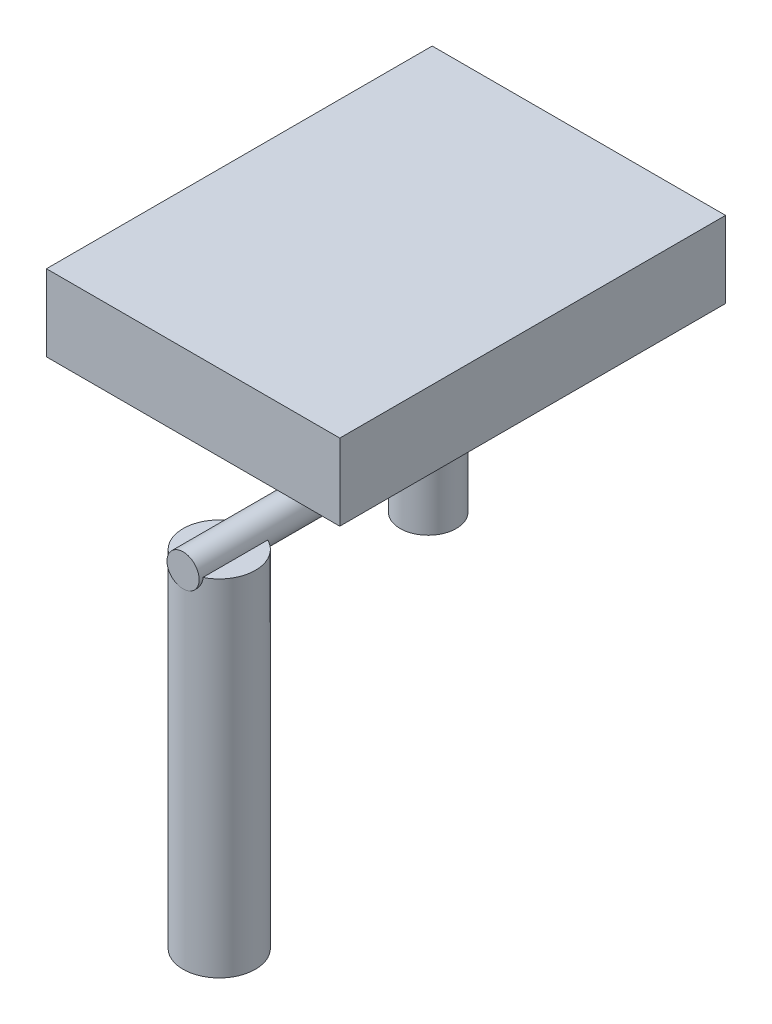
from build123d import *

# Parameters (mm, degrees)
ESQUISSE1_W        = 365
ESQUISSE1_H        = 95
BOSS_EXTRU_1_DEPTH = 480
ESQUISSE3_R        = 35
BOSS_EXTRU_2_DEPTH = 235
BOSS_EXTRU_3_REACH = 482
ESQUISSE4_R        = 20
BOSS_EXTRU_4_START = 145
ESQUISSE5_R        = 45
BOSS_EXTRU_4_DEPTH = 430
ESQUISSE6_W        = 205
ESQUISSE6_H        = 70
BOSS_EXTRU_5_DEPTH = 55
ESQUISSE7_R        = 60
BOSS_EXTRU_6_DEPTH = 50


with BuildPart() as part:
    # Esquisse1 → Boss.-Extru.1 (new body)
    with BuildSketch(Plane.XY):
        with Locations((103.348235656, -10.607228484)):
            Rectangle(ESQUISSE1_W, ESQUISSE1_H)
    extrude(amount=BOSS_EXTRU_1_DEPTH)

    # Esquisse3 → Boss.-Extru.2 (add)
    with BuildSketch(Plane.XZ.offset(58.107228484)):
        with Locations((90.848235656, 175)):
            Circle(ESQUISSE3_R)
    extrude(amount=BOSS_EXTRU_2_DEPTH)

    # Esquisse4 → Boss.-Extru.3 (add, up to next)
    with BuildSketch(Plane.XY.offset(480), mode=Mode.PRIVATE) as boss_extru_3_sk1:
        with Locations((90.848235656, -203.107228484)):
            Circle(ESQUISSE4_R)
    boss_extru_3_tool1 = extrude(boss_extru_3_sk1.sketch, amount=-BOSS_EXTRU_3_REACH, mode=Mode.PRIVATE) - part.part
    add(boss_extru_3_tool1.solids().sort_by_distance((90.848236, -203.107228, 480))[0])

    # Esquisse6 → Boss.-Extru.5 (add)
    with BuildSketch(Plane.XZ.offset(58.107228484)):
        with Locations((23.348235656, 175)):
            Rectangle(ESQUISSE6_W, ESQUISSE6_H)
    extrude(amount=BOSS_EXTRU_5_DEPTH)

    # Esquisse7 → Boss.-Extru.6 (add)
    with BuildSketch(Plane.XZ.offset(58.107228484)):
        with Locations((90.848235656, 175)):
            Circle(ESQUISSE7_R)
    extrude(amount=BOSS_EXTRU_6_DEPTH)


with BuildPart() as body_2:
    # Esquisse5 → Boss.-Extru.4 (new body)
    with BuildSketch(Plane.XZ.offset(58.107228484).offset(BOSS_EXTRU_4_START)):
        with Locations((90.848235656, 435)):
            Circle(ESQUISSE5_R)
    extrude(amount=BOSS_EXTRU_4_DEPTH)


solid = Compound([part.part, body_2.part])
